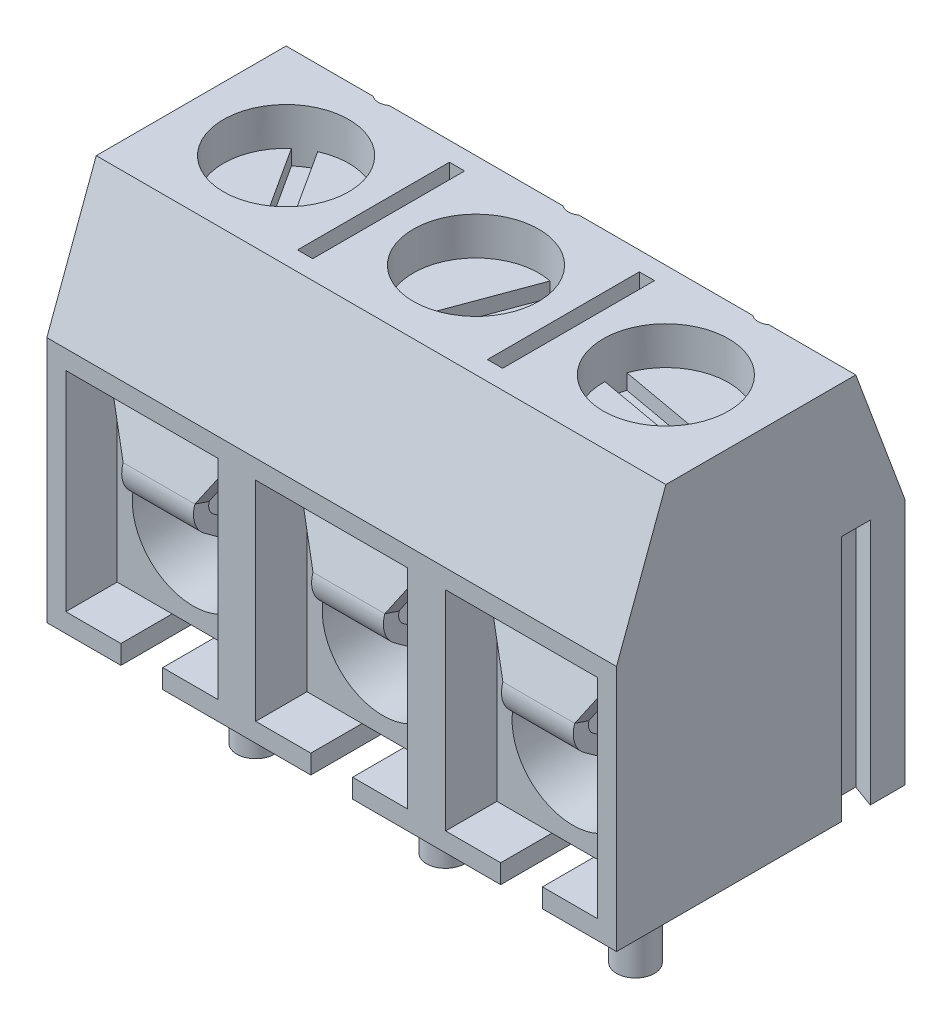
from build123d import *

# Parameters (mm, degrees)
SKETCH1_W               = 15
SKETCH1_H               = 7.6
EXTRUDE1_DEPTH          = 10
SKETCH2_OUTSIDE_W       = 13.512
SKETCH2_OUTSIDE_H       = 15.912
CUT_EXTRUDE1_DEPTH      = 11
CUT_EXTRUDE1_DEPTH_BACK = 6
SKETCH3_R               = 1.65
SKETCH3_R_2             = 0.35
SKETCH3_W               = 0.4
SKETCH3_H               = 4
CUT_EXTRUDE2_DEPTH      = 4
SKETCH4_W               = 4
SKETCH4_H               = 5.5
CUT_EXTRUDE3_DEPTH      = 5.6
EXTRUDE3_DEPTH          = 6.5
CUT_EXTRUDE5_DEPTH      = 6.5
SKETCH10_W              = 1.1
SKETCH10_H              = 0.5
CUT_EXTRUDE6_DEPTH      = 3.6
SKETCH5_W               = 4
SKETCH5_H               = 5.1
EXTRUDE2_DEPTH          = 4.25
SKETCH6_R               = 1.6
CUT_EXTRUDE4_DEPTH      = 4.25
SKETCH11_R              = 0.5
EXTRUDE4_DEPTH          = 3.5
SKETCH12_R              = 1.65
EXTRUDE5_DEPTH          = 3
CUT_EXTRUDE7_DEPTH      = 0.4
EXTRUDE6_DEPTH          = 0.945
EXTRUDE9_DEPTH          = 0.39
LPATTERN1_COUNT         = 3
LPATTERN1_PITCH         = 5
FILLET1_R               = 0.3
FILLET2_R               = 0.7


with BuildPart() as part:
    # Sketch1 → Extrude1 (new body)
    with BuildSketch(Plane(origin=(0, 0, 0), x_dir=(1, 0, 0), z_dir=(0, 1, 0))):
        with Locations((2.5, 0)):
            Rectangle(SKETCH1_W, SKETCH1_H)
    extrude(amount=EXTRUDE1_DEPTH)

    # Sketch2 outside → Cut-Extrude1 (cut, two sides)
    with BuildSketch(Plane(origin=(0, 0, 0), x_dir=(0, 0, -1), z_dir=(1, 0, 0))) as cut_extrude1_sk:
        with Locations((0, 5)):
            Rectangle(SKETCH2_OUTSIDE_W, SKETCH2_OUTSIDE_H)
        Polygon((2.5, 10), (3.8, 6.5), (3.8, 0), (-3.8, 0), (-3.8, 6.5), (-2.5, 10), align=None, mode=Mode.SUBTRACT)
    extrude(amount=CUT_EXTRUDE1_DEPTH, mode=Mode.SUBTRACT)
    extrude(cut_extrude1_sk.sketch, amount=-CUT_EXTRUDE1_DEPTH_BACK, mode=Mode.SUBTRACT)

    # Sketch3 → Cut-Extrude2 (cut)
    with BuildSketch(Plane(origin=(0, 10, 0), x_dir=(-1, 0, 0), z_dir=(0, 1, 0))):
        with Locations((2.5, 0)):
            Circle(SKETCH3_R)
        with Locations((-2.5, 0)):
            Circle(SKETCH3_R)
        with Locations((2.5, -2.78)):
            Circle(SKETCH3_R_2)
        with Locations((-2.5, -2.78)):
            Circle(SKETCH3_R_2)
        with Locations((-7.5, 0)):
            Circle(SKETCH3_R)
        with Locations((-7.5, -2.78)):
            Circle(SKETCH3_R_2)
        Rectangle(SKETCH3_W, SKETCH3_H)
        with Locations((-5, 0)):
            Rectangle(SKETCH3_W, SKETCH3_H)
    extrude(amount=-CUT_EXTRUDE2_DEPTH, mode=Mode.SUBTRACT)

    # Sketch4 → Cut-Extrude3 (cut)
    with BuildSketch(Plane.XY.offset(3.8)):
        with Locations((-2.5, 3.25)):
            Rectangle(SKETCH4_W, SKETCH4_H)
        with Locations((2.5, 3.25)):
            Rectangle(SKETCH4_W, SKETCH4_H)
        with Locations((7.5, 3.25)):
            Rectangle(SKETCH4_W, SKETCH4_H)
    extrude(amount=-CUT_EXTRUDE3_DEPTH, mode=Mode.SUBTRACT)

    # Sketch7 → Extrude3 (add)
    with BuildSketch(Plane(origin=(0, 0, 0), x_dir=(1, 0, 0), z_dir=(0, 1, 0))):
        Polygon((-5.6, 3.1), (-5, 2.881617859), (-5, 2.118382141), (-5.6, 1.9), align=None)
    extrude(amount=EXTRUDE3_DEPTH)

    # Sketch9 → Cut-Extrude5 (cut)
    with BuildSketch(Plane(origin=(0, 0, 0), x_dir=(1, 0, 0), z_dir=(0, 1, 0))):
        Polygon((10, 2.881617859), (9.4, 3.1), (9.4, 1.9), (10, 2.118382141), align=None)
    extrude(amount=CUT_EXTRUDE5_DEPTH, mode=Mode.SUBTRACT)

    # Sketch10 → Cut-Extrude6 (cut)
    with BuildSketch(Plane.XY.offset(3.8)):
        with Locations((-2.5, 0.25)):
            Rectangle(SKETCH10_W, SKETCH10_H)
        with Locations((2.5, 0.25)):
            Rectangle(SKETCH10_W, SKETCH10_H)
        with Locations((7.5, 0.25)):
            Rectangle(SKETCH10_W, SKETCH10_H)
    extrude(amount=-CUT_EXTRUDE6_DEPTH, mode=Mode.SUBTRACT)

    # Sketch5 → Extrude2 (add)
    with BuildSketch(Plane.XY.offset(-1.8)):
        with Locations((-2.5, 3.05)):
            Rectangle(SKETCH5_W, SKETCH5_H)
        with Locations((2.5, 3.05)):
            Rectangle(SKETCH5_W, SKETCH5_H)
        with Locations((7.5, 3.05)):
            Rectangle(SKETCH5_W, SKETCH5_H)
    extrude(amount=EXTRUDE2_DEPTH)

    # Sketch6 → Cut-Extrude4 (cut)
    with BuildSketch(Plane.XY.offset(2.45)):
        with Locations((-2.5, 2.554263468)):
            Circle(SKETCH6_R)
        with Locations((2.5, 2.554263468)):
            Circle(SKETCH6_R)
        with Locations((7.5, 2.554263468)):
            Circle(SKETCH6_R)
    extrude(amount=-CUT_EXTRUDE4_DEPTH, mode=Mode.SUBTRACT)

    # Sketch11 → Extrude4 (add)
    with BuildSketch(Plane.XZ.offset(-0.5)):
        with Locations((-2.5, 0.8)):
            Circle(SKETCH11_R)
        with Locations((2.5, 0.8)):
            Circle(SKETCH11_R)
        with Locations((7.5, 0.8)):
            Circle(SKETCH11_R)
    extrude(amount=EXTRUDE4_DEPTH)

    # Sketch12 → Extrude5 (add)
    with BuildSketch(Plane.XZ.offset(-6)):
        with Locations((2.5, 0)):
            Circle(SKETCH12_R)
        with Locations((-2.5, 0)):
            Circle(SKETCH12_R)
        with Locations((7.5, 0)):
            Circle(SKETCH12_R)
    extrude(amount=-EXTRUDE5_DEPTH)

    # Sketch13 → Cut-Extrude7 (cut)
    with BuildSketch(Plane(origin=(0, 9, 0), x_dir=(-1, 0, 0), z_dir=(0, 1, 0))):
        with BuildLine():
            Line((3.594307251, -1.234905519), (1.825829895, 1.505986278))
            ThreePointArc((1.825829895, 1.505986278), (1.605433494, 1.386452583), (1.405692749, 1.234905519))
            Line((1.405692749, 1.234905519), (3.174170105, -1.505986278))
            ThreePointArc((3.174170105, -1.505986278), (3.394566506, -1.386452583), (3.594307251, -1.234905519))
        make_face()
        with BuildLine():
            Line((-5.938894906, -0.534276038), (-9.149461674, 0.042144841))
            ThreePointArc((-9.149461674, 0.042144841), (-9.12403295, 0.291576712), (-9.061105094, 0.534276038))
            Line((-9.061105094, 0.534276038), (-5.850538326, -0.042144841))
            ThreePointArc((-5.850538326, -0.042144841), (-5.87596705, -0.291576712), (-5.938894906, -0.534276038))
        make_face()
        with BuildLine():
            Line((-2.83217089, -1.616218581), (-1.698971441, 1.44251629))
            ThreePointArc((-1.698971441, 1.44251629), (-1.926782442, 1.54723031), (-2.16782911, 1.616218581))
            Line((-2.16782911, 1.616218581), (-3.301028559, -1.44251629))
            ThreePointArc((-3.301028559, -1.44251629), (-3.073217558, -1.54723031), (-2.83217089, -1.616218581))
        make_face()
    extrude(amount=-CUT_EXTRUDE7_DEPTH, mode=Mode.SUBTRACT)

    # Sketch14 → Extrude6 (add, symmetric)
    with BuildSketch(Plane.ZY.offset(2.5)):
        Polygon((2.45, 5.6), (3.03887637, 3.861674443), (0.167170254, 1.787608865), (-0.546359637, 2.097431054), (-0.705673534, 1.730526322), (0.216750724, 1.33), (3.512480259, 3.710312924), (2.736824279, 6), (-1.8, 6), (-1.8, 5.6), align=None)
    extrude6 = extrude(amount=EXTRUDE6_DEPTH, both=True)

    # Sketch15 → Extrude9 (add)
    with BuildSketch(Plane(origin=(0, 1.449355072, 4.278403908), x_dir=(1, 0, 0), z_dir=(0, 0.320850379, 0.947129893))):
        Polygon((-1.555, 4.8), (-1.555, 2.903968921), (-0.51, 4.8), align=None)
        Polygon((-3.445, 4.8), (-3.445, 2.903968921), (-4.49, 4.8), align=None)
    extrude9 = extrude(amount=-EXTRUDE9_DEPTH)

    # LPattern1: Extrude6, Extrude9 ×3
    with Locations(*[(i * LPATTERN1_PITCH, 0, 0) for i in range(1, LPATTERN1_COUNT)]):
        add(extrude6)
        add(extrude9)

    # Fillet1
    fillet1_edges = [part.edges().sort_by_distance(p)[0] for p in [
        (-2.5, 3.861674443, 3.03887637),
        (-2.5, 1.787608865, 0.167170254),
        (2.5, 3.861674443, 3.03887637),
        (2.5, 1.787608865, 0.167170254),
        (7.5, 3.861674443, 3.03887637),
        (7.5, 1.787608865, 0.167170254),
    ]]
    fillet(fillet1_edges, radius=FILLET1_R)

    # Fillet2
    fillet2_edges = [part.edges().sort_by_distance(p)[0] for p in [
        (-2.5, 3.710312924, 3.512480259),
        (-2.5, 1.33, 0.216750724),
        (2.5, 1.33, 0.216750724),
        (2.5, 3.710312924, 3.512480259),
        (7.5, 3.710312924, 3.512480259),
        (7.5, 1.33, 0.216750724),
    ]]
    fillet(fillet2_edges, radius=FILLET2_R)


solid = part.part
